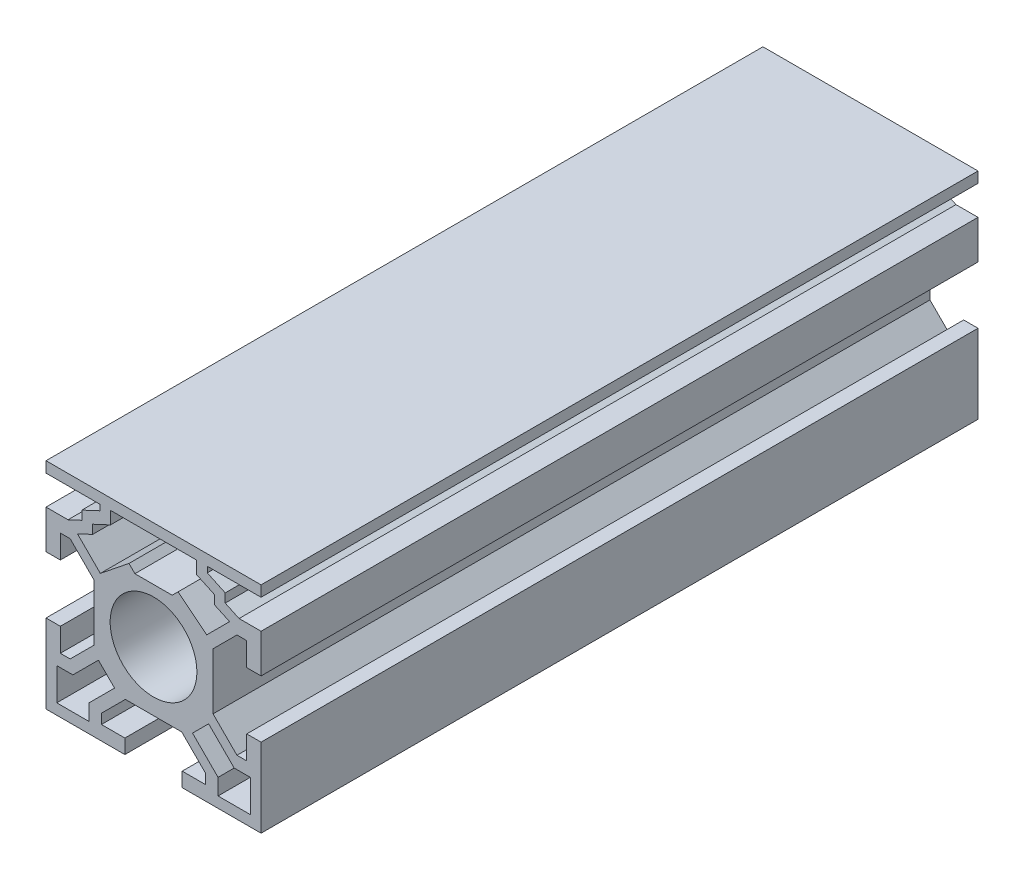
from build123d import *

# Parameters (mm, degrees)
SKETCH1_R          = 6.05
SKETCH1_W          = 4.5
SKETCH1_H          = 4.5
EXTRUDE1_DEPTH     = 100
CUT_EXTRUDE1_DEPTH = 101
CIRPATTERN1_COUNT  = 2
CIRPATTERN1_ANGLE  = 90


with BuildPart() as part:
    # Sketch1 → Extrude1 (new body)
    with BuildSketch(Plane.XY):
        Polygon((13, 7.265685), (11.634315, 7.265685), (8.3, 3.931371213), (8.3, -3.931371213), (11.634315, -7.265685), (13, -7.265685), (13, -4), (15, -4), (15, -15), (4, -15), (4, -13), (7.265685, -13), (7.265685, -11.634315), (3.931371213, -8.3), (-3.931371213, -8.3), (-7.265685, -11.634315), (-7.265685, -13), (-4, -13), (-4, -15), (-15, -15), (-15, -4), (-13, -4), (-13, -7.265685), (-11.634315, -7.265685), (-8.3, -3.931371213), (-8.3, 3.931371213), (-11.634315, 7.265685), (-13, 7.265685), (-13, 4), (-15, 4), (-15, 9.399999971), (-11.93005553, 9.399999971), (-9.99999999, 10.299999926), (-9.99999999, 11.534231082), (-7.49999999, 12.69999986), (-7.49999999, 13.499999971), (-14.999999992, 13.499999971), (-14.999999992, 15), (14.99999999, 15), (14.99999999, 13.499999971), (7.49999999, 13.499999971), (7.49999999, 12.69999986), (9.99999999, 11.534231082), (9.99999999, 10.299999926), (11.93005553, 9.399999971), (15, 9.399999971), (15, 4), (13, 4), align=None)
        Circle(SKETCH1_R, mode=Mode.SUBTRACT)
        Polygon((-8.5, 10.5786251), (-8.5, 9.344394771), (-10.60849553, 8.361187544), (-7.423547516, 5.176238259), (-3.426503445, 8.376249899), (-2.600251667, 7.55), (2.600251667, 7.55), (3.426503445, 8.376249899), (7.423547516, 5.176238259), (10.60849553, 8.361187544), (8.5, 9.344394771), (8.5, 10.5786251), (6, 11.7443949), (6, 13.5), (-6, 13.5), (-6, 11.7443949), align=None, mode=Mode.SUBTRACT)
        with Locations((-11.25, -11.25)):
            Rectangle(SKETCH1_W, SKETCH1_H, mode=Mode.SUBTRACT)
        with Locations((11.25, -11.25)):
            Rectangle(SKETCH1_W, SKETCH1_H, mode=Mode.SUBTRACT)
    extrude(amount=-EXTRUDE1_DEPTH)

    # Sketch2 → Cut-Extrude1 (cut, through all)
    with BuildSketch(Plane.XY):
        Polygon((-11.25, -9), (-7.686853797, -5.436853797), (-5.436853797, -7.686853797), (-9, -11.25), align=None)
    cut_extrude1 = extrude(amount=-CUT_EXTRUDE1_DEPTH, mode=Mode.SUBTRACT)

    # CirPattern1: Cut-Extrude1 ×2 about axis
    cirpattern1_axis = Axis((0, 0, 0), (0, 0, 1))
    for i in range(1, CIRPATTERN1_COUNT):
        add(cut_extrude1.rotate(cirpattern1_axis, i * CIRPATTERN1_ANGLE / (CIRPATTERN1_COUNT - 1)), mode=Mode.SUBTRACT)


solid = part.part
